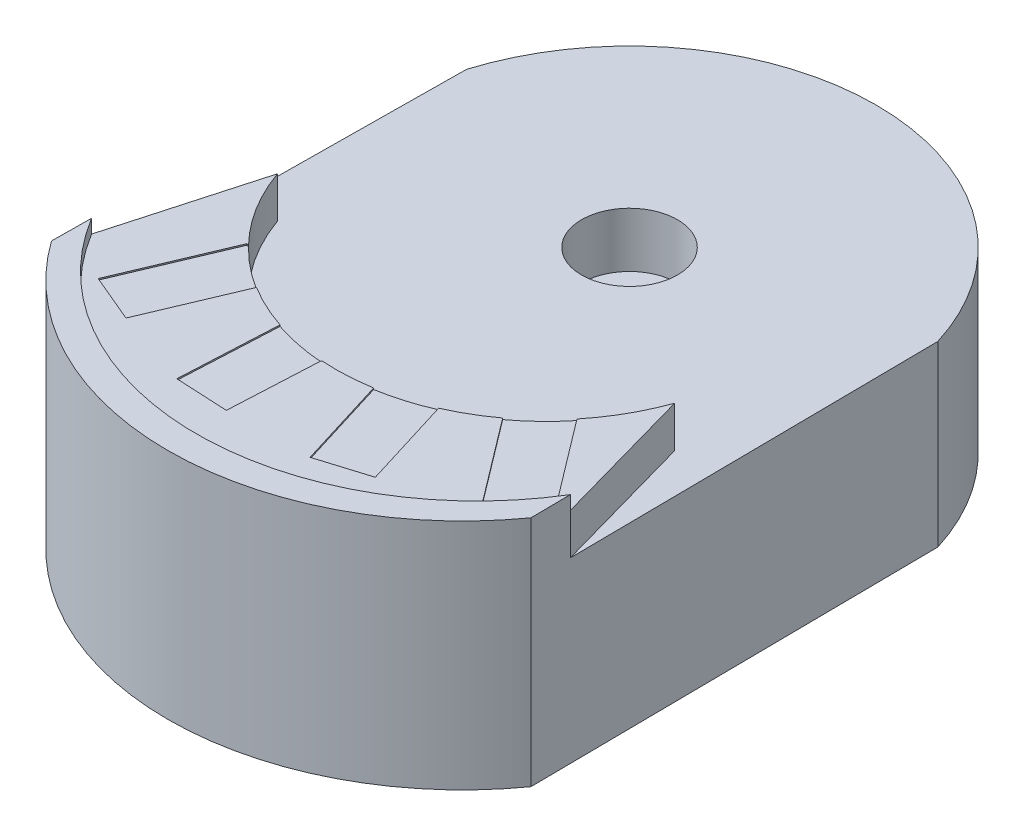
from build123d import *

# Parameters (mm, degrees)
BOSS_EXTRUDE1_DEPTH = 130
BOSS_EXTRUDE2_DEPTH = 40
SKETCH4_R           = 35
CUT_EXTRUDE1_DEPTH  = 40
BOSS_EXTRUDE3_DEPTH = 30
CUT_EXTRUDE2_DEPTH  = 1
CIRPATTERN1_COUNT   = 4
CIRPATTERN1_ANGLE   = 60


with BuildPart() as part:
    # Sketch2 → Boss-Extrude1 (new body)
    with BuildSketch(Plane(origin=(0, 0, 0), x_dir=(1, 0, 0), z_dir=(0, 1, 0))):
        with BuildLine():
            Line((-172, 150), (-175, -150))
            ThreePointArc((-175, -150), (0, -240), (175, -150))
            Line((175, -150), (172, 150))
            ThreePointArc((172, 150), (0, 276.934003354), (-172, 150))
        make_face()
    extrude(amount=BOSS_EXTRUDE1_DEPTH)

    # Sketch3 → Boss-Extrude2 (add)
    with BuildSketch(Plane(origin=(0, 130, 0), x_dir=(1, 0, 0), z_dir=(0, 1, 0))):
        with BuildLine():
            Line((-175, -150), (-174.71, -121))
            ThreePointArc((-174.71, -121), (0, -219.05898872), (174.71, -121))
            Line((174.71, -121), (175, -150))
            ThreePointArc((175, -150), (0, -240), (-175, -150))
        make_face()
    extrude(amount=BOSS_EXTRUDE2_DEPTH)

    # Sketch4 → Cut-Extrude1 (cut)
    with BuildSketch(Plane(origin=(0, 130, 0), x_dir=(1, 0, 0), z_dir=(0, 1, 0))):
        with Locations((0, 96.934003354)):
            Circle(SKETCH4_R)
    extrude(amount=-CUT_EXTRUDE1_DEPTH, mode=Mode.SUBTRACT)

    # Sketch5 → Boss-Extrude3 (add)
    with BuildSketch(Plane(origin=(0, 130, 0), x_dir=(1, 0, 0), z_dir=(0, 1, 0))):
        with BuildLine():
            Line((-174.71, -121), (-145, -15.088169216))
            ThreePointArc((-145, -15.088169216), (0, -117.466388714), (145, -15.088169216))
            Line((145, -15.088169216), (174.71, -121))
            ThreePointArc((174.71, -121), (0, -219.05898872), (-174.71, -121))
        make_face()
    extrude(amount=BOSS_EXTRUDE3_DEPTH)

    # Sketch6 → Cut-Extrude2 (cut)
    with BuildSketch(Plane(origin=(0, 160, 0), x_dir=(1, 0, 0), z_dir=(0, 1, 0))):
        Polygon((169.306747394, -126.764048286), (119.216917014, -60.582412673), (88.83715416, -83.575455293), (138.92698454, -149.757090907), align=None)
    cut_extrude2 = extrude(amount=-CUT_EXTRUDE2_DEPTH, mode=Mode.SUBTRACT)

    # CirPattern1: Cut-Extrude2 ×4 about axis
    cirpattern1_axis = Axis((0, 0, -96.934003354), (0, -1, 0))
    for i in range(1, CIRPATTERN1_COUNT):
        add(cut_extrude2.rotate(cirpattern1_axis, i * CIRPATTERN1_ANGLE / (CIRPATTERN1_COUNT - 1)), mode=Mode.SUBTRACT)


solid = part.part
